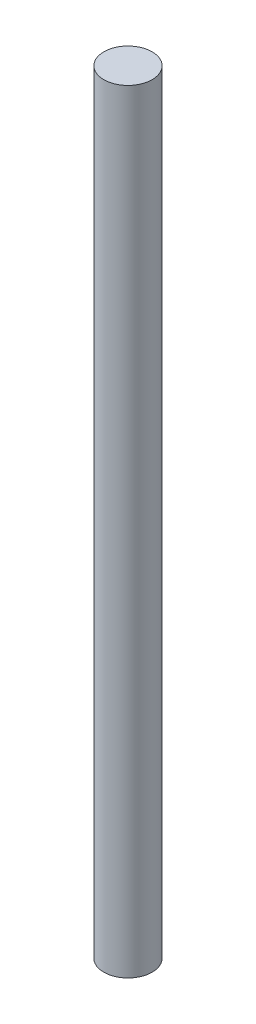
from build123d import *

# Parameters (mm, degrees)
SKETCH2_R           = 1.27
BOSS_EXTRUDE1_DEPTH = 20.32


with BuildPart() as part:
    # Sketch2 → Boss-Extrude1 (new body, symmetric)
    with BuildSketch(Plane(origin=(0, 0, 0), x_dir=(1, 0, 0), z_dir=(0, 1, 0))):
        Circle(SKETCH2_R)
    extrude(amount=BOSS_EXTRUDE1_DEPTH, both=True)


solid = part.part
